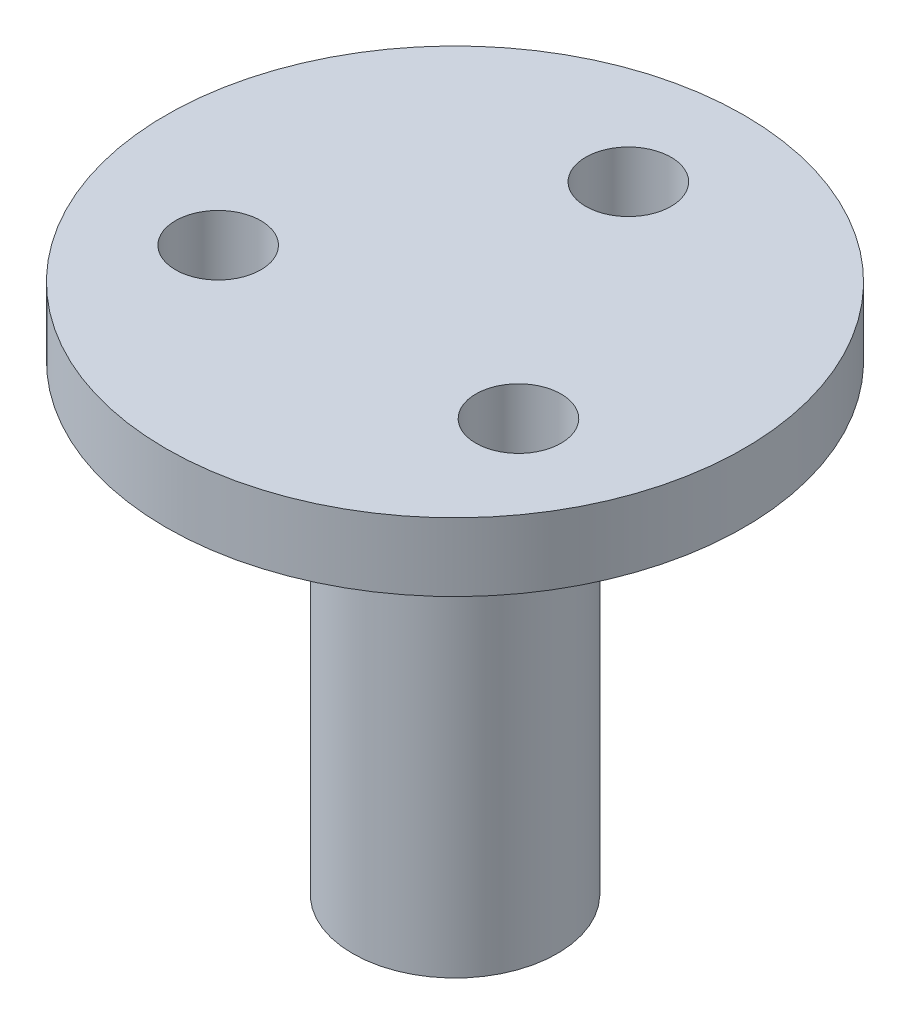
from build123d import *

# Parameters (mm, degrees)
SKETCH1_R           = 4.5
BOSS_EXTRUDE1_DEPTH = 20.32
SKETCH2_R           = 12.7
SKETCH2_R_2         = 1.875
BOSS_EXTRUDE2_DEPTH = 3
CUT_EXTRUDE1_DEPTH  = 5.842


with BuildPart() as part:
    # Sketch1 → Boss-Extrude1 (new body)
    with BuildSketch(Plane(origin=(0, 0, 0), x_dir=(1, 0, 0), z_dir=(0, 1, 0))):
        Circle(SKETCH1_R)
    extrude(amount=BOSS_EXTRUDE1_DEPTH)

    # Sketch2 → Boss-Extrude2 (add)
    with BuildSketch(Plane(origin=(0, 20.32, 0), x_dir=(1, 0, 0), z_dir=(0, 1, 0))):
        Circle(SKETCH2_R)
        with Locations((0, 7.62)):
            Circle(SKETCH2_R_2, mode=Mode.SUBTRACT)
        with Locations((6.599113577, -3.81)):
            Circle(SKETCH2_R_2, mode=Mode.SUBTRACT)
        with Locations((-6.599113577, -3.81)):
            Circle(SKETCH2_R_2, mode=Mode.SUBTRACT)
    extrude(amount=BOSS_EXTRUDE2_DEPTH)

    # Sketch3 → Cut-Extrude1 (cut)
    with BuildSketch(Plane.XZ):
        with BuildLine():
            Line((1.4605, 2.078109658), (1.4605, -2.078109658))
            ThreePointArc((1.4605, -2.078109658), (0, -2.54), (-1.4605, -2.078109658))
            Line((-1.4605, -2.078109658), (-1.4605, 2.078109658))
            ThreePointArc((-1.4605, 2.078109658), (0, 2.54), (1.4605, 2.078109658))
        make_face()
    extrude(amount=-CUT_EXTRUDE1_DEPTH, mode=Mode.SUBTRACT)


solid = part.part
